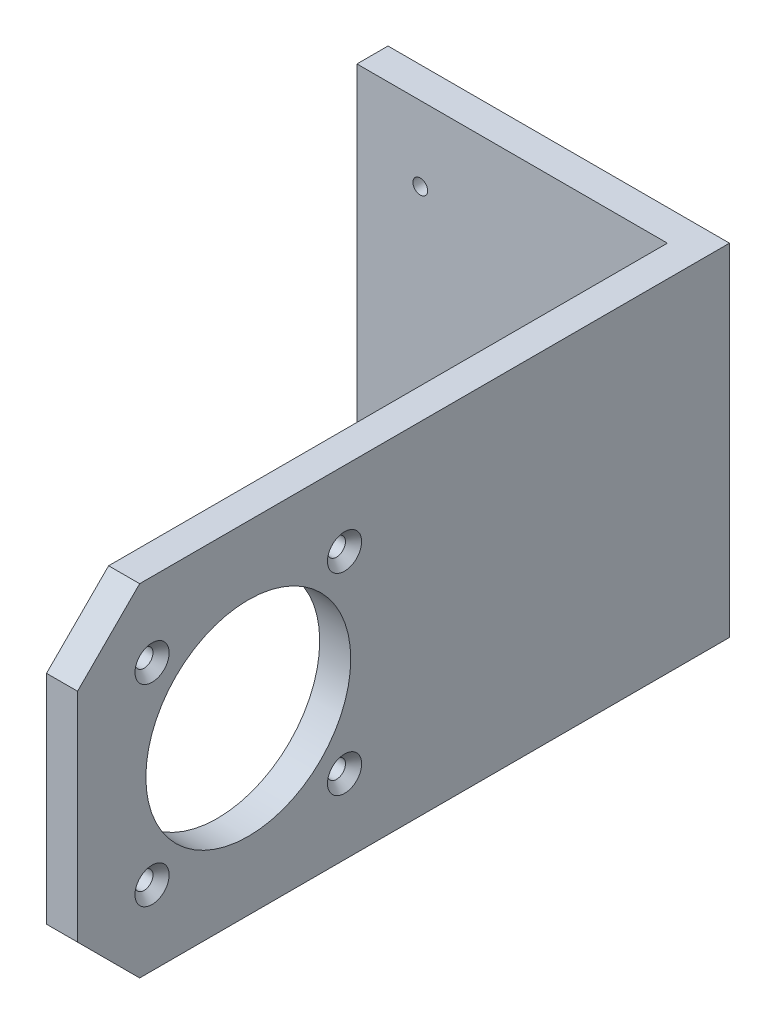
from build123d import *

# Parameters (mm, degrees)
SKETCH1_W                                         = 55
SKETCH1_H                                         = 55
BOSS_EXTRUDE1_DEPTH                               = 5
SKETCH2_W                                         = 5
SKETCH2_H                                         = 55
BOSS_EXTRUDE2_DEPTH                               = 100
CUT_EXTRUDE1_REACH                                = 57
SKETCH3_R                                         = 16.5
CUT_EXTRUDE2_REACH                                = 7
SKETCH4_R                                         = 2.5
CUT_EXTRUDE3_REACH                                = 57
F_4_48_TAPPED_HOLE1_D                             = 2.3749
F_4_48_TAPPED_HOLE1_DEPTH                         = 3.5
F_4_48_TAPPED_HOLE1_TIP                           = 0.713491942
CSK_FOR_M2_5_FLAT_HEAD_MACHINE_SCREW1_D           = 2.9
CSK_FOR_M2_5_FLAT_HEAD_MACHINE_SCREW1_DEPTH       = 5
CSK_FOR_M2_5_FLAT_HEAD_MACHINE_SCREW1_CSINK_D     = 5.5
CSK_FOR_M2_5_FLAT_HEAD_MACHINE_SCREW1_CSINK_ANGLE = 90


with BuildPart() as part:
    # Sketch1 → Boss-Extrude1 (new body)
    with BuildSketch(Plane.XY):
        Rectangle(SKETCH1_W, SKETCH1_H)
    extrude(amount=BOSS_EXTRUDE1_DEPTH)

    # Sketch2 → Boss-Extrude2 (add)
    with BuildSketch(Plane.XY.offset(5)):
        with Locations((25, 0)):
            Rectangle(SKETCH2_W, SKETCH2_H)
    extrude(amount=BOSS_EXTRUDE2_DEPTH)

    # Sketch3 → Cut-Extrude1 (cut, up to next)
    with BuildSketch(Plane(origin=(27.5, 0, 0), x_dir=(0, 0, -1), z_dir=(1, 0, 0)), mode=Mode.PRIVATE) as cut_extrude1_sk1:
        with Locations((-77.5, 0)):
            Circle(SKETCH3_R)
    cut_extrude1_tool1 = extrude(cut_extrude1_sk1.sketch, amount=-CUT_EXTRUDE1_REACH, mode=Mode.PRIVATE) & part.part
    add(cut_extrude1_tool1.solids().sort_by_distance((27.5, 0, 77.5))[0], mode=Mode.SUBTRACT)

    # Sketch4 → Cut-Extrude2 (cut, up to next)
    with BuildSketch(Plane.XY.offset(5), mode=Mode.PRIVATE) as cut_extrude2_sk1:
        Circle(SKETCH4_R)
    cut_extrude2_tool1 = extrude(cut_extrude2_sk1.sketch, amount=-CUT_EXTRUDE2_REACH, mode=Mode.PRIVATE) & part.part
    add(cut_extrude2_tool1.solids().sort_by_distance((0, 0, 5))[0], mode=Mode.SUBTRACT)

    # Sketch5 → Cut-Extrude3 (cut, up to next)
    with BuildSketch(Plane(origin=(27.5, 0, 0), x_dir=(0, 0, -1), z_dir=(1, 0, 0)), mode=Mode.PRIVATE) as cut_extrude3_sk1:
        Polygon((-105, 27.5), (-95, 27.5), (-105, 17.5), align=None)
    cut_extrude3_tool1 = extrude(cut_extrude3_sk1.sketch, amount=-CUT_EXTRUDE3_REACH, mode=Mode.PRIVATE) & part.part
    add(cut_extrude3_tool1.solids().sort_by_distance((27.5, 24.166667, 101.666667))[0], mode=Mode.SUBTRACT)
    # Sketch5 → Cut-Extrude3 (cut, up to next)
    with BuildSketch(Plane(origin=(27.5, 0, 0), x_dir=(0, 0, -1), z_dir=(1, 0, 0)), mode=Mode.PRIVATE) as cut_extrude3_sk2:
        Polygon((-105, -27.5), (-95, -27.5), (-105, -17.5), align=None)
    cut_extrude3_tool2 = extrude(cut_extrude3_sk2.sketch, amount=-CUT_EXTRUDE3_REACH, mode=Mode.PRIVATE) & part.part
    add(cut_extrude3_tool2.solids().sort_by_distance((27.5, -24.166667, 101.666667))[0], mode=Mode.SUBTRACT)

    # #4-48 Tapped Hole1
    with Locations(Plane.XY.offset(5)):
        with Locations((-17.3, 15.5), (-17.3, -15.5)):
            Hole(F_4_48_TAPPED_HOLE1_D / 2, depth=F_4_48_TAPPED_HOLE1_DEPTH)
            with Locations((0, 0, -(F_4_48_TAPPED_HOLE1_DEPTH + F_4_48_TAPPED_HOLE1_TIP / 2))):  # 118° drill point
                Cone(0, F_4_48_TAPPED_HOLE1_D / 2, F_4_48_TAPPED_HOLE1_TIP, mode=Mode.SUBTRACT)

    # CSK for M2.5 Flat Head Machine Screw1
    with Locations(Plane(origin=(27.5, 0, 0), x_dir=(0, 0, -1), z_dir=(1, 0, 0))):
        with Locations((-93, 15.5), (-62, 15.5), (-62, -15.5), (-93, -15.5)):
            CounterSinkHole(CSK_FOR_M2_5_FLAT_HEAD_MACHINE_SCREW1_D / 2, CSK_FOR_M2_5_FLAT_HEAD_MACHINE_SCREW1_CSINK_D / 2, depth=CSK_FOR_M2_5_FLAT_HEAD_MACHINE_SCREW1_DEPTH, counter_sink_angle=CSK_FOR_M2_5_FLAT_HEAD_MACHINE_SCREW1_CSINK_ANGLE)


solid = part.part
